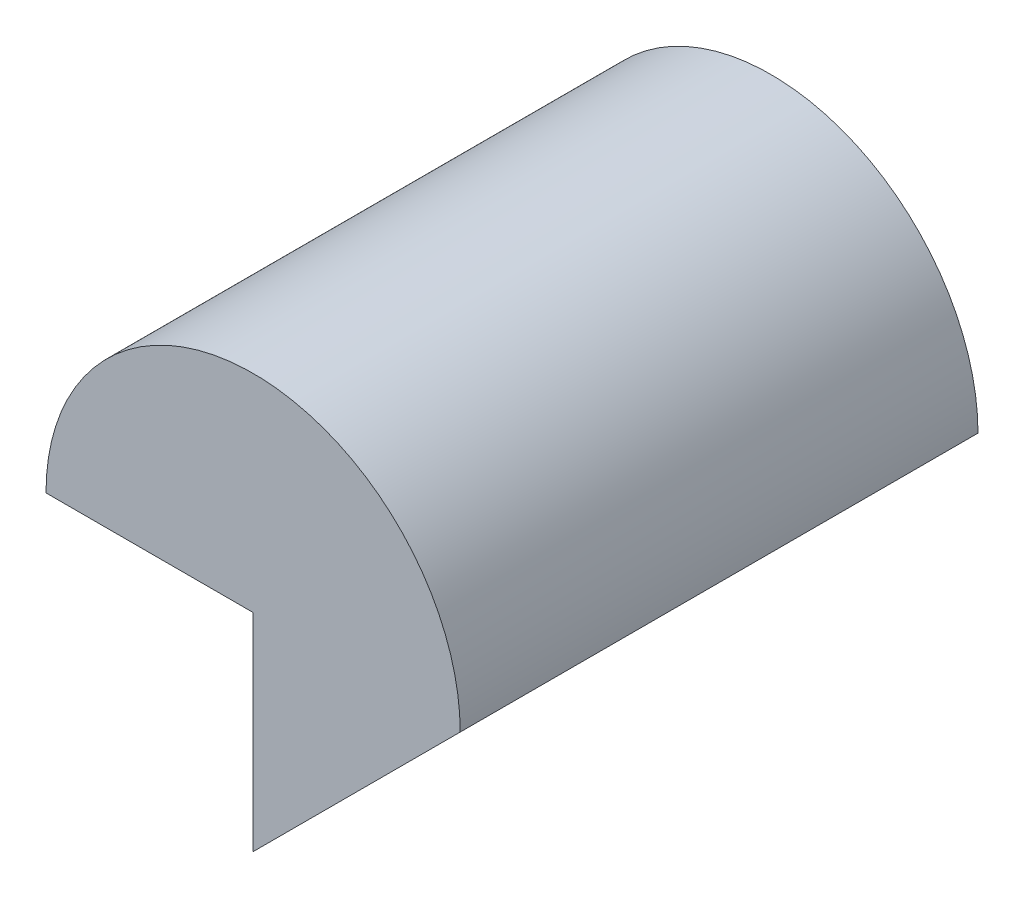
from build123d import *

# Parameters (mm, degrees)
BOSS_EXTRUDE1_DEPTH = 25


with BuildPart() as part:
    # Sketch1 → Boss-Extrude1 (new body)
    with BuildSketch(Plane.XY):
        with BuildLine():
            Line((-10, -10), (-10, 0))
            Line((-10, 0), (-20, 0))
            ThreePointArc((-20, 0), (-10, 10), (0, 0))
            Line((0, 0), (-10, -10))
        make_face()
    extrude(amount=BOSS_EXTRUDE1_DEPTH)


solid = part.part
